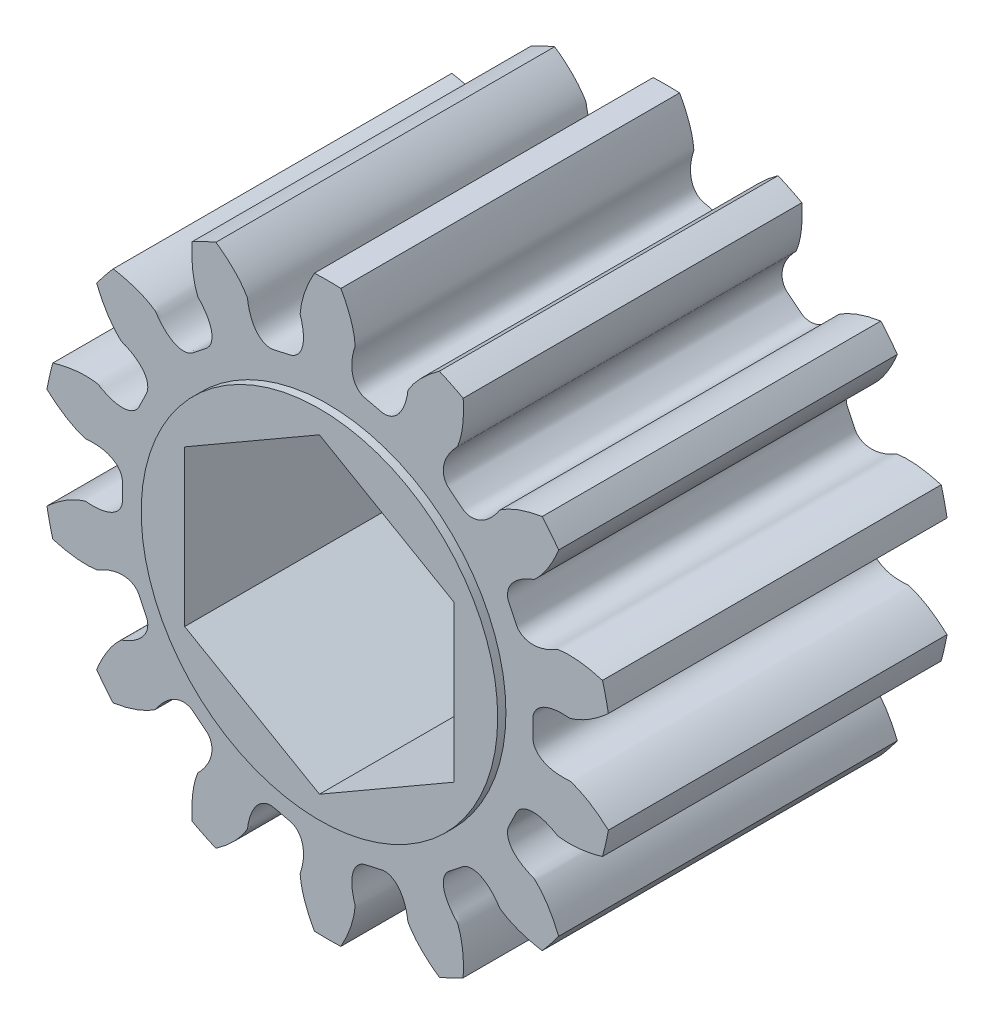
from build123d import *

# Parameters (mm, degrees)
BOSS_EXTRUDE1_DEPTH = 12.065
SKETCH2_R           = 6.35
BOSS_EXTRUDE2_DEPTH = 0.2921
SKETCH3_R           = 6.35
BOSS_EXTRUDE3_DEPTH = 0.2921
CUT_EXTRUDE1_DEPTH  = 13.6492


with BuildPart() as part:
    # Sketch1 → Boss-Extrude1 (new body)
    with BuildSketch(Plane.XY.offset(6.0325)):
        with BuildLine():
            ThreePointArc((8.228776346, 5.959265042), (7.943407862, 6.334656387), (7.640928824, 6.69640252))
            add(Edge.make_bspline(
                [(4.82824311, 8.939444528), (4.833892588, 8.852687386), (4.83956114, 8.714236491), (4.839397518, 8.527056628), (4.834597301, 8.381215605), (4.825704165, 8.244427954), (4.813292608, 8.116797302), (4.797939964, 7.998399272), (4.780222678, 7.889283272), (4.760723014, 7.789466905), (4.740002099, 7.698954413), (4.718682579, 7.617677092), (4.697178715, 7.545684876), (4.676542333, 7.482543191), (4.650701206, 7.415927439), (4.621669261, 7.324730091), (4.540040809, 7.261231409), (4.481952223, 7.188233595), (4.43551344, 7.130936279), (4.39285588, 7.073433212), (4.35314075, 7.016307214), (4.316544651, 6.959436941), (4.282987183, 6.902864935), (4.252459951, 6.846571912), (4.224945594, 6.790531236), (4.200443436, 6.734690952), (4.178969629, 6.678974044), (4.160566483, 6.623273893), (4.145313008, 6.567451505), (4.133339922, 6.5113341), (4.12484958, 6.454717507), (4.120141721, 6.397375872), (4.119644468, 6.339084418), (4.123947256, 6.279663842), (4.133825193, 6.219056118), (4.150237388, 6.157442121), (4.174255479, 6.095387744), (4.206926479, 6.034019633), (4.248882322, 5.975011401), (4.295645816, 5.925851012), (4.399067692, 5.839116758), (4.564695196, 5.723946729), (4.713833258, 5.588099595), (4.821406436, 5.506570908), (4.879740128, 5.471919088), (4.946604954, 5.444145733), (5.01370442, 5.425949552), (5.079547492, 5.416342044), (5.143268754, 5.41405174), (5.204554963, 5.417907952), (5.263443202, 5.426935365), (5.320162519, 5.44039122), (5.375018882, 5.457740758), (5.4283267, 5.478616606), (5.480372862, 5.502776799), (5.531401448, 5.530069487), (5.581609996, 5.560405678), (5.631151593, 5.593739269), (5.680139601, 5.63005274), (5.7286527, 5.669347478), (5.776741391, 5.711635705), (5.82442778, 5.756940272), (5.871728798, 5.805273657), (5.918585081, 5.856704777), (5.965154226, 5.911088458), (6.010681377, 5.969112777), (6.068923056, 6.041988502), (6.112665655, 6.135700144), (6.195116279, 6.184297517), (6.254311643, 6.224314153), (6.311278208, 6.258483483), (6.376680368, 6.295467976), (6.451175858, 6.334338877), (6.534808176, 6.374681199), (6.627782855, 6.415903197), (6.730220622, 6.457456868), (6.842233881, 6.498770629), (6.963902735, 6.539271495), (7.095281925, 6.578379777), (7.23639826, 6.615512324), (7.418848724, 6.657323281), (7.555089737, 6.682605074), (7.640928824, 6.69640252)],
                knots=[0.010313213, 0.010313213, 0.010313213, 0.010313213, 0.046086444, 0.067310464, 0.087321683, 0.106120101, 0.123705718, 0.140078533, 0.155238548, 0.169185761, 0.181920174, 0.193441785, 0.203750595, 0.212846604, 0.220729812, 0.233281794, 0.251264484, 0.261666579, 0.271771633, 0.281588016, 0.291125391, 0.300394957, 0.309409753, 0.318185016, 0.32673863, 0.335091659, 0.343268986, 0.351300066, 0.359219801, 0.367069473, 0.374897695, 0.382761153, 0.390724829, 0.398861066, 0.407246569, 0.415956082, 0.425051594, 0.434566975, 0.44449066, 0.454752968, 0.462386324, 0.5, 0.537613676, 0.545247032, 0.55550934, 0.565433025, 0.574948406, 0.584043918, 0.592753431, 0.601138934, 0.609275171, 0.617238847, 0.625102305, 0.632930527, 0.640780199, 0.648699934, 0.656731014, 0.664908341, 0.67326137, 0.681814984, 0.690590247, 0.699605043, 0.708874609, 0.718411984, 0.728228367, 0.738333421, 0.748735516, 0.766718206, 0.779270188, 0.787153396, 0.796249405, 0.806558215, 0.818079826, 0.830814239, 0.844761452, 0.859921467, 0.876294282, 0.893879899, 0.912678317, 0.932689536, 0.953913556, 0.989686787, 0.989686787, 0.989686787, 0.989686787], degree=3))
            ThreePointArc((4.82824311, 8.939444528), (4.408258789, 9.153843698), (3.978778828, 9.348524966))
            add(Edge.make_bspline(
                [(0.471417111, 10.14905739), (0.514149629, 10.073343122), (0.579328409, 9.951062669), (0.66039529, 9.782348447), (0.719348491, 9.648867489), (0.770685991, 9.521767488), (0.814880429, 9.40139107), (0.852419155, 9.288056869), (0.883800089, 9.182059508), (0.909540197, 9.083667481), (0.930143197, 8.993128076), (0.946199881, 8.910649547), (0.958061821, 8.836456624), (0.966865234, 8.770614142), (0.972486674, 8.699383378), (0.985898842, 8.604620918), (0.939905194, 8.511993324), (0.919241751, 8.421020874), (0.902262226, 8.349248743), (0.888778739, 8.278931848), (0.877782684, 8.210231353), (0.869485825, 8.143114555), (0.863797265, 8.077584899), (0.860717807, 8.013621369), (0.860243365, 7.951192432), (0.862395875, 7.890250987), (0.867223304, 7.830734652), (0.874810032, 7.772565723), (0.885287552, 7.715653255), (0.898848604, 7.659898293), (0.91576409, 7.605204685), (0.936402058, 7.551498993), (0.961245763, 7.498764457), (0.990904063, 7.447095278), (1.026100482, 7.396775482), (1.06762067, 7.348384173), (1.116184607, 7.30289617), (1.172246787, 7.261780829), (1.235650407, 7.226820207), (1.299112753, 7.202818146), (1.429925226, 7.169546354), (1.629120853, 7.137644824), (1.822431467, 7.079959365), (1.954725523, 7.053178809), (2.022317225, 7.047268639), (2.094610758, 7.051257271), (2.162960315, 7.063976446), (2.226451415, 7.083888618), (2.284856014, 7.109472745), (2.338399833, 7.139538162), (2.387539455, 7.173222229), (2.432803517, 7.209955125), (2.47469971, 7.249387802), (2.513670703, 7.291325687), (2.55007996, 7.335675252), (2.584213274, 7.382405588), (2.616287232, 7.431522224), (2.646459766, 7.483050046), (2.674840612, 7.537022452), (2.701500055, 7.593474833), (2.726478295, 7.652440109), (2.749785332, 7.713948463), (2.771431007, 7.778018481), (2.791331932, 7.844686497), (2.809693087, 7.913890096), (2.825535825, 7.985921691), (2.846390172, 8.076850568), (2.845140934, 8.180261043), (2.89834077, 8.259819748), (2.934311383, 8.321557397), (2.970810967, 8.377059766), (3.013689307, 8.438758577), (3.063941972, 8.50610243), (3.12178821, 8.578736309), (3.187669946, 8.656216247), (3.261933723, 8.738100893), (3.344928813, 8.823924037), (3.436975996, 8.913204193), (3.538376109, 9.005442832), (3.649406325, 9.100126183), (3.795647418, 9.216958844), (3.90742697, 9.298849712), (3.978778828, 9.348524966)],
                knots=[0.010313213, 0.010313213, 0.010313213, 0.010313213, 0.046086444, 0.067310464, 0.087321683, 0.106120101, 0.123705718, 0.140078533, 0.155238548, 0.169185761, 0.181920174, 0.193441785, 0.203750595, 0.212846604, 0.220729812, 0.233281794, 0.251264484, 0.261666579, 0.271771633, 0.281588016, 0.291125391, 0.300394957, 0.309409753, 0.318185016, 0.32673863, 0.335091659, 0.343268986, 0.351300066, 0.359219801, 0.367069473, 0.374897695, 0.382761153, 0.390724829, 0.398861066, 0.407246569, 0.415956082, 0.425051594, 0.434566975, 0.44449066, 0.454752968, 0.462386324, 0.5, 0.537613676, 0.545247032, 0.55550934, 0.565433025, 0.574948406, 0.584043918, 0.592753431, 0.601138934, 0.609275171, 0.617238847, 0.625102305, 0.632930527, 0.640780199, 0.648699934, 0.656731014, 0.664908341, 0.67326137, 0.681814984, 0.690590247, 0.699605043, 0.708874609, 0.718411984, 0.728228367, 0.738333421, 0.748735516, 0.766718206, 0.779270188, 0.787153396, 0.796249405, 0.806558215, 0.818079826, 0.830814239, 0.844761452, 0.859921467, 0.876294282, 0.893879899, 0.912678317, 0.932689536, 0.953913556, 0.989686787, 0.989686787, 0.989686787, 0.989686787], degree=3))
            ThreePointArc((0.471417111, 10.14905739), (0, 10.16), (-0.471417111, 10.14905739))
            add(Edge.make_bspline(
                [(-3.978778828, 9.348524966), (-3.90742697, 9.298849712), (-3.795647418, 9.216958844), (-3.649406325, 9.100126183), (-3.538376109, 9.005442832), (-3.436975996, 8.913204193), (-3.344928813, 8.823924037), (-3.261933723, 8.738100893), (-3.187669946, 8.656216247), (-3.12178821, 8.578736309), (-3.063941972, 8.50610243), (-3.013689307, 8.438758577), (-2.970810967, 8.377059766), (-2.934311383, 8.321557397), (-2.89834077, 8.259819748), (-2.845140934, 8.180261043), (-2.846390172, 8.076850568), (-2.825535825, 7.985921691), (-2.809693087, 7.913890096), (-2.791331932, 7.844686497), (-2.771431007, 7.778018481), (-2.749785332, 7.713948463), (-2.726478295, 7.652440109), (-2.701500055, 7.593474833), (-2.674840612, 7.537022452), (-2.646459766, 7.483050046), (-2.616287232, 7.431522224), (-2.584213274, 7.382405588), (-2.55007996, 7.335675252), (-2.513670703, 7.291325687), (-2.47469971, 7.249387802), (-2.432803517, 7.209955125), (-2.387539455, 7.173222229), (-2.338399833, 7.139538162), (-2.284856014, 7.109472745), (-2.226451415, 7.083888618), (-2.162960315, 7.063976446), (-2.094610758, 7.051257271), (-2.022317225, 7.047268639), (-1.954725523, 7.053178809), (-1.822431467, 7.079959365), (-1.629120854, 7.137644824), (-1.429925226, 7.169546354), (-1.299112753, 7.202818146), (-1.235650407, 7.226820207), (-1.172246787, 7.261780829), (-1.116184607, 7.30289617), (-1.06762067, 7.348384173), (-1.026100482, 7.396775482), (-0.990904063, 7.447095278), (-0.961245763, 7.498764457), (-0.936402058, 7.551498993), (-0.91576409, 7.605204685), (-0.898848604, 7.659898293), (-0.885287552, 7.715653255), (-0.874810032, 7.772565723), (-0.867223304, 7.830734652), (-0.862395875, 7.890250987), (-0.860243365, 7.951192432), (-0.860717807, 8.013621369), (-0.863797265, 8.077584899), (-0.869485825, 8.143114555), (-0.877782684, 8.210231353), (-0.888778739, 8.278931848), (-0.902262226, 8.349248743), (-0.919241751, 8.421020874), (-0.939905194, 8.511993324), (-0.985898842, 8.604620918), (-0.972486674, 8.699383378), (-0.966865234, 8.770614142), (-0.958061821, 8.836456624), (-0.946199881, 8.910649547), (-0.930143197, 8.993128076), (-0.909540197, 9.083667481), (-0.883800089, 9.182059508), (-0.852419155, 9.288056869), (-0.814880429, 9.40139107), (-0.770685991, 9.521767488), (-0.719348492, 9.648867489), (-0.66039529, 9.782348447), (-0.579328409, 9.951062669), (-0.514149629, 10.073343122), (-0.471417111, 10.14905739)],
                knots=[0.010313213, 0.010313213, 0.010313213, 0.010313213, 0.046086444, 0.067310464, 0.087321683, 0.106120101, 0.123705718, 0.140078533, 0.155238548, 0.169185761, 0.181920174, 0.193441785, 0.203750595, 0.212846604, 0.220729812, 0.233281794, 0.251264484, 0.261666579, 0.271771633, 0.281588016, 0.291125391, 0.300394957, 0.309409753, 0.318185016, 0.32673863, 0.335091659, 0.343268986, 0.351300066, 0.359219801, 0.367069473, 0.374897695, 0.382761153, 0.390724829, 0.398861066, 0.407246569, 0.415956082, 0.425051594, 0.434566975, 0.44449066, 0.454752968, 0.462386324, 0.5, 0.537613676, 0.545247032, 0.55550934, 0.565433025, 0.574948406, 0.584043918, 0.592753431, 0.601138934, 0.609275171, 0.617238847, 0.625102305, 0.632930527, 0.640780199, 0.648699934, 0.656731014, 0.664908341, 0.67326137, 0.681814984, 0.690590247, 0.699605043, 0.708874609, 0.718411984, 0.728228367, 0.738333421, 0.748735516, 0.766718206, 0.779270188, 0.787153396, 0.796249405, 0.806558215, 0.818079826, 0.830814239, 0.844761452, 0.859921467, 0.876294282, 0.893879899, 0.912678317, 0.932689536, 0.953913556, 0.989686787, 0.989686787, 0.989686787, 0.989686787], degree=3))
            ThreePointArc((-3.978778828, 9.348524966), (-4.408258789, 9.153843698), (-4.82824311, 8.939444528))
            add(Edge.make_bspline(
                [(-7.640928824, 6.69640252), (-7.555089737, 6.682605074), (-7.418848724, 6.657323281), (-7.23639826, 6.615512324), (-7.095281925, 6.578379777), (-6.963902735, 6.539271495), (-6.842233881, 6.498770629), (-6.730220622, 6.457456868), (-6.627782855, 6.415903197), (-6.534808176, 6.374681199), (-6.451175858, 6.334338877), (-6.376680368, 6.295467976), (-6.311278208, 6.258483483), (-6.254311643, 6.224314153), (-6.195116279, 6.184297517), (-6.112665655, 6.135700144), (-6.068923056, 6.041988502), (-6.010681377, 5.969112777), (-5.965154226, 5.911088458), (-5.918585081, 5.856704777), (-5.871728798, 5.805273657), (-5.82442778, 5.756940272), (-5.776741391, 5.711635705), (-5.7286527, 5.669347478), (-5.680139601, 5.63005274), (-5.631151593, 5.59373927), (-5.581609996, 5.560405678), (-5.531401448, 5.530069487), (-5.480372862, 5.502776799), (-5.4283267, 5.478616606), (-5.375018882, 5.457740758), (-5.320162519, 5.44039122), (-5.263443202, 5.426935365), (-5.204554963, 5.417907952), (-5.143268754, 5.41405174), (-5.079547492, 5.416342044), (-5.01370442, 5.425949552), (-4.946604954, 5.444145733), (-4.879740128, 5.471919088), (-4.821406436, 5.506570908), (-4.713833258, 5.588099595), (-4.564695196, 5.723946729), (-4.399067692, 5.839116758), (-4.295645816, 5.925851012), (-4.248882322, 5.975011401), (-4.206926479, 6.034019633), (-4.174255479, 6.095387744), (-4.150237388, 6.157442121), (-4.133825193, 6.219056118), (-4.123947257, 6.279663842), (-4.119644468, 6.339084418), (-4.120141721, 6.397375872), (-4.12484958, 6.454717507), (-4.133339922, 6.5113341), (-4.145313008, 6.567451505), (-4.160566483, 6.623273893), (-4.178969629, 6.678974044), (-4.200443436, 6.734690952), (-4.224945594, 6.790531236), (-4.252459951, 6.846571912), (-4.282987183, 6.902864935), (-4.316544651, 6.959436941), (-4.35314075, 7.016307214), (-4.39285588, 7.073433212), (-4.43551344, 7.130936279), (-4.481952223, 7.188233595), (-4.540040809, 7.261231409), (-4.621669261, 7.324730091), (-4.650701206, 7.415927439), (-4.676542333, 7.482543191), (-4.697178715, 7.545684876), (-4.718682579, 7.617677092), (-4.740002099, 7.698954413), (-4.760723014, 7.789466905), (-4.780222678, 7.889283272), (-4.797939964, 7.998399272), (-4.813292608, 8.116797302), (-4.825704165, 8.244427954), (-4.834597301, 8.381215605), (-4.839397518, 8.527056628), (-4.83956114, 8.714236491), (-4.833892588, 8.852687386), (-4.82824311, 8.939444528)],
                knots=[0.010313213, 0.010313213, 0.010313213, 0.010313213, 0.046086444, 0.067310464, 0.087321683, 0.106120101, 0.123705718, 0.140078533, 0.155238548, 0.169185761, 0.181920174, 0.193441785, 0.203750595, 0.212846604, 0.220729812, 0.233281794, 0.251264484, 0.261666579, 0.271771633, 0.281588016, 0.291125391, 0.300394957, 0.309409753, 0.318185016, 0.32673863, 0.335091659, 0.343268986, 0.351300066, 0.359219801, 0.367069473, 0.374897695, 0.382761153, 0.390724829, 0.398861066, 0.407246569, 0.415956082, 0.425051594, 0.434566975, 0.44449066, 0.454752968, 0.462386324, 0.5, 0.537613676, 0.545247032, 0.55550934, 0.565433025, 0.574948406, 0.584043918, 0.592753431, 0.601138934, 0.609275171, 0.617238847, 0.625102305, 0.632930527, 0.640780199, 0.648699934, 0.656731014, 0.664908341, 0.67326137, 0.681814984, 0.690590247, 0.699605043, 0.708874609, 0.718411984, 0.728228367, 0.738333421, 0.748735516, 0.766718206, 0.779270188, 0.787153396, 0.796249405, 0.806558215, 0.818079826, 0.830814239, 0.844761452, 0.859921467, 0.876294282, 0.893879899, 0.912678317, 0.932689536, 0.953913556, 0.989686787, 0.989686787, 0.989686787, 0.989686787], degree=3))
            ThreePointArc((-7.640928824, 6.69640252), (-7.943407862, 6.334656387), (-8.228776346, 5.959265042))
            add(Edge.make_bspline(
                [(-9.789699156, 2.717975429), (-9.706374323, 2.742788544), (-9.572656053, 2.779123196), (-9.390132771, 2.820615114), (-9.246880138, 2.848387928), (-9.111543131, 2.870155878), (-8.984350614, 2.886455996), (-8.865504785, 2.897834316), (-8.755182084, 2.904841833), (-8.653529238, 2.908042297), (-8.560675246, 2.907981824), (-8.476691677, 2.905282734), (-8.401719397, 2.900337791), (-8.335568779, 2.894269154), (-8.264873031, 2.883899317), (-8.169501975, 2.875888583), (-8.089431298, 2.810436512), (-8.005337766, 2.77004787), (-7.939143412, 2.737523256), (-7.873589867, 2.708730847), (-7.809058689, 2.682723189), (-7.745470874, 2.659699456), (-7.682850007, 2.6395718), (-7.62117542, 2.622336326), (-7.56041728, 2.607982034), (-7.500524786, 2.596519828), (-7.441426445, 2.587982593), (-7.383027728, 2.582435302), (-7.325210706, 2.579985914), (-7.26783602, 2.580800315), (-7.210749644, 2.585121221), (-7.153798086, 2.593291112), (-7.096857471, 2.605777395), (-7.039884153, 2.623194626), (-6.98299404, 2.646311389), (-6.926576891, 2.6760225), (-6.871422875, 2.713246805), (-6.818863372, 2.758754365), (-6.770670653, 2.812788854), (-6.733148673, 2.869319105), (-6.671602561, 2.989448166), (-6.596175672, 3.176550785), (-6.49692085, 3.352178476), (-6.441373542, 3.475196409), (-6.420570983, 3.539778309), (-6.408372787, 3.611146847), (-6.405563859, 3.68061302), (-6.410848692, 3.746943141), (-6.422795126, 3.809576419), (-6.440192119, 3.868467967), (-6.462097062, 3.923870966), (-6.487836786, 3.976174002), (-6.516958024, 4.025794366), (-6.549172576, 4.073120332), (-6.584308384, 4.11848544), (-6.622271716, 4.162161438), (-6.663019767, 4.204360715), (-6.706541659, 4.245242779), (-6.752845532, 4.284922048), (-6.80195025, 4.32347492), (-6.853878962, 4.360947912), (-6.90865887, 4.397357489), (-6.966305902, 4.432717382), (-7.02687404, 4.466954379), (-7.090256819, 4.500254431), (-7.156957091, 4.531728495), (-7.240965662, 4.57229356), (-7.342061402, 4.594086638), (-7.407787327, 4.66365612), (-7.45997287, 4.712462794), (-7.505961757, 4.760397696), (-7.556572321, 4.815930264), (-7.611045453, 4.879908407), (-7.668986251, 4.952466877), (-7.729863539, 5.033937729), (-7.793169921, 5.124560606), (-7.858373155, 5.224572282), (-7.924932446, 5.334178353), (-7.992294822, 5.453561182), (-8.059897717, 5.582876666), (-8.141259434, 5.751448903), (-8.196223837, 5.878648341), (-8.228776346, 5.959265042)],
                knots=[0.010313213, 0.010313213, 0.010313213, 0.010313213, 0.046086444, 0.067310464, 0.087321683, 0.106120101, 0.123705718, 0.140078533, 0.155238548, 0.169185761, 0.181920174, 0.193441785, 0.203750595, 0.212846604, 0.220729812, 0.233281794, 0.251264484, 0.261666579, 0.271771633, 0.281588016, 0.291125391, 0.300394957, 0.309409753, 0.318185016, 0.32673863, 0.335091659, 0.343268986, 0.351300066, 0.359219801, 0.367069473, 0.374897695, 0.382761153, 0.390724829, 0.398861066, 0.407246569, 0.415956082, 0.425051594, 0.434566975, 0.44449066, 0.454752968, 0.462386324, 0.5, 0.537613676, 0.545247032, 0.55550934, 0.565433025, 0.574948406, 0.584043918, 0.592753431, 0.601138934, 0.609275171, 0.617238847, 0.625102305, 0.632930527, 0.640780199, 0.648699934, 0.656731014, 0.664908341, 0.67326137, 0.681814984, 0.690590247, 0.699605043, 0.708874609, 0.718411984, 0.728228367, 0.738333421, 0.748735516, 0.766718206, 0.779270188, 0.787153396, 0.796249405, 0.806558215, 0.818079826, 0.830814239, 0.844761452, 0.859921467, 0.876294282, 0.893879899, 0.912678317, 0.932689536, 0.953913556, 0.989686787, 0.989686787, 0.989686787, 0.989686787], degree=3))
            ThreePointArc((-9.789699156, 2.717975429), (-9.905267588, 2.260812689), (-9.999499508, 1.798780029))
            add(Edge.make_bspline(
                [(-9.999499508, -1.798780029), (-9.935192434, -1.740270896), (-9.830481451, -1.649516322), (-9.684036324, -1.532939511), (-9.567020335, -1.445762082), (-9.454530664, -1.36742931), (-9.347006522, -1.297556647), (-9.244866998, -1.235739863), (-9.148510127, -1.181559082), (-9.058312707, -1.134570046), (-8.974627912, -1.094336693), (-8.89779024, -1.060329384), (-8.828097019, -1.03225537), (-8.765864289, -1.009021346), (-8.697670317, -0.987690511), (-8.608268238, -0.953527983), (-8.507728461, -0.977756896), (-8.414438832, -0.977658989), (-8.340687878, -0.978242), (-8.269133617, -0.975740447), (-8.199708734, -0.971173509), (-8.13242847, -0.964327456), (-8.067275956, -0.955291671), (-8.00423088, -0.944060697), (-7.943261594, -0.930631498), (-7.884327057, -0.914972209), (-7.827377124, -0.897022183), (-7.772354818, -0.876681866), (-7.719200732, -0.853802823), (-7.667861282, -0.828175129), (-7.618303005, -0.799513277), (-7.570536207, -0.767442106), (-7.524652081, -0.731486746), (-7.480877949, -0.691074567), (-7.439651715, -0.645563388), (-7.401712789, -0.594316118), (-7.368171757, -0.536847748), (-7.340562272, -0.47304214), (-7.320586818, -0.40344871), (-7.31130824, -0.336236537), (-7.307979155, -0.201300135), (-7.32120266, 0), (-7.307979155, 0.201300135), (-7.31130824, 0.336236537), (-7.320586818, 0.40344871), (-7.340562272, 0.47304214), (-7.368171757, 0.536847748), (-7.401712789, 0.594316118), (-7.439651715, 0.645563388), (-7.480877949, 0.691074567), (-7.524652081, 0.731486746), (-7.570536207, 0.767442106), (-7.618303005, 0.799513277), (-7.667861282, 0.828175129), (-7.719200732, 0.853802823), (-7.772354818, 0.876681866), (-7.827377124, 0.897022183), (-7.884327057, 0.914972209), (-7.943261594, 0.930631498), (-8.00423088, 0.944060697), (-8.067275956, 0.955291671), (-8.13242847, 0.964327456), (-8.199708734, 0.971173509), (-8.269133617, 0.975740447), (-8.340687878, 0.978242), (-8.414438832, 0.977658989), (-8.507728461, 0.977756896), (-8.608268238, 0.953527983), (-8.697670317, 0.987690511), (-8.765864289, 1.009021346), (-8.828097019, 1.03225537), (-8.89779024, 1.060329384), (-8.974627912, 1.094336693), (-9.058312707, 1.134570046), (-9.148510127, 1.181559082), (-9.244866998, 1.235739863), (-9.347006522, 1.297556647), (-9.454530664, 1.36742931), (-9.567020335, 1.445762082), (-9.684036324, 1.532939511), (-9.830481451, 1.649516322), (-9.935192434, 1.740270896), (-9.999499508, 1.798780029)],
                knots=[0.010313213, 0.010313213, 0.010313213, 0.010313213, 0.046086444, 0.067310464, 0.087321683, 0.106120101, 0.123705718, 0.140078533, 0.155238548, 0.169185761, 0.181920174, 0.193441785, 0.203750595, 0.212846604, 0.220729812, 0.233281794, 0.251264484, 0.261666579, 0.271771633, 0.281588016, 0.291125391, 0.300394957, 0.309409753, 0.318185016, 0.32673863, 0.335091659, 0.343268986, 0.351300066, 0.359219801, 0.367069473, 0.374897695, 0.382761153, 0.390724829, 0.398861066, 0.407246569, 0.415956082, 0.425051594, 0.434566975, 0.44449066, 0.454752968, 0.462386324, 0.5, 0.537613676, 0.545247032, 0.55550934, 0.565433025, 0.574948406, 0.584043918, 0.592753431, 0.601138934, 0.609275171, 0.617238847, 0.625102305, 0.632930527, 0.640780199, 0.648699934, 0.656731014, 0.664908341, 0.67326137, 0.681814984, 0.690590247, 0.699605043, 0.708874609, 0.718411984, 0.728228367, 0.738333421, 0.748735516, 0.766718206, 0.779270188, 0.787153396, 0.796249405, 0.806558215, 0.818079826, 0.830814239, 0.844761452, 0.859921467, 0.876294282, 0.893879899, 0.912678317, 0.932689536, 0.953913556, 0.989686787, 0.989686787, 0.989686787, 0.989686787], degree=3))
            ThreePointArc((-9.999499508, -1.798780029), (-9.905267588, -2.260812689), (-9.789699156, -2.717975429))
            add(Edge.make_bspline(
                [(-8.228776346, -5.959265042), (-8.196223837, -5.878648341), (-8.141259434, -5.751448903), (-8.059897717, -5.582876666), (-7.992294822, -5.453561182), (-7.924932446, -5.334178353), (-7.858373155, -5.224572282), (-7.793169921, -5.124560606), (-7.729863539, -5.033937729), (-7.668986251, -4.952466877), (-7.611045453, -4.879908407), (-7.556572321, -4.815930264), (-7.505961757, -4.760397696), (-7.45997287, -4.712462794), (-7.407787327, -4.66365612), (-7.342061402, -4.594086638), (-7.240965662, -4.57229356), (-7.156957091, -4.531728495), (-7.090256819, -4.500254431), (-7.02687404, -4.466954379), (-6.966305902, -4.432717382), (-6.90865887, -4.397357489), (-6.853878962, -4.360947912), (-6.801950249, -4.32347492), (-6.752845532, -4.284922048), (-6.706541659, -4.245242779), (-6.663019767, -4.204360715), (-6.622271716, -4.162161438), (-6.584308383, -4.11848544), (-6.549172576, -4.073120332), (-6.516958024, -4.025794366), (-6.487836786, -3.976174002), (-6.462097062, -3.923870966), (-6.440192119, -3.868467967), (-6.422795126, -3.809576419), (-6.410848692, -3.746943141), (-6.405563859, -3.68061302), (-6.408372787, -3.611146847), (-6.420570983, -3.539778309), (-6.441373542, -3.475196409), (-6.49692085, -3.352178476), (-6.596175672, -3.176550785), (-6.671602561, -2.989448166), (-6.733148673, -2.869319105), (-6.770670653, -2.812788854), (-6.818863372, -2.758754365), (-6.871422875, -2.713246805), (-6.926576891, -2.6760225), (-6.98299404, -2.646311389), (-7.039884153, -2.623194626), (-7.096857471, -2.605777395), (-7.153798086, -2.593291112), (-7.210749644, -2.585121221), (-7.26783602, -2.580800315), (-7.325210706, -2.579985914), (-7.383027728, -2.582435302), (-7.441426445, -2.587982593), (-7.500524786, -2.596519828), (-7.56041728, -2.607982034), (-7.62117542, -2.622336326), (-7.682850007, -2.6395718), (-7.745470874, -2.659699456), (-7.809058689, -2.682723189), (-7.873589867, -2.708730847), (-7.939143412, -2.737523256), (-8.005337766, -2.77004787), (-8.089431298, -2.810436512), (-8.169501975, -2.875888583), (-8.264873031, -2.883899317), (-8.335568779, -2.894269154), (-8.401719397, -2.900337791), (-8.476691677, -2.905282734), (-8.560675246, -2.907981824), (-8.653529238, -2.908042297), (-8.755182084, -2.904841833), (-8.865504785, -2.897834316), (-8.984350614, -2.886455996), (-9.111543131, -2.870155878), (-9.246880138, -2.848387928), (-9.390132771, -2.820615114), (-9.572656053, -2.779123196), (-9.706374323, -2.742788544), (-9.789699156, -2.717975429)],
                knots=[0.010313213, 0.010313213, 0.010313213, 0.010313213, 0.046086444, 0.067310464, 0.087321683, 0.106120101, 0.123705718, 0.140078533, 0.155238548, 0.169185761, 0.181920174, 0.193441785, 0.203750595, 0.212846604, 0.220729812, 0.233281794, 0.251264484, 0.261666579, 0.271771633, 0.281588016, 0.291125391, 0.300394957, 0.309409753, 0.318185016, 0.32673863, 0.335091659, 0.343268986, 0.351300066, 0.359219801, 0.367069473, 0.374897695, 0.382761153, 0.390724829, 0.398861066, 0.407246569, 0.415956082, 0.425051594, 0.434566975, 0.44449066, 0.454752968, 0.462386324, 0.5, 0.537613676, 0.545247032, 0.55550934, 0.565433025, 0.574948406, 0.584043918, 0.592753431, 0.601138934, 0.609275171, 0.617238847, 0.625102305, 0.632930527, 0.640780199, 0.648699934, 0.656731014, 0.664908341, 0.67326137, 0.681814984, 0.690590247, 0.699605043, 0.708874609, 0.718411984, 0.728228367, 0.738333421, 0.748735516, 0.766718206, 0.779270188, 0.787153396, 0.796249405, 0.806558215, 0.818079826, 0.830814239, 0.844761452, 0.859921467, 0.876294282, 0.893879899, 0.912678317, 0.932689536, 0.953913556, 0.989686787, 0.989686787, 0.989686787, 0.989686787], degree=3))
            ThreePointArc((-8.228776346, -5.959265042), (-7.943407862, -6.334656387), (-7.640928824, -6.69640252))
            add(Edge.make_bspline(
                [(-4.82824311, -8.939444528), (-4.833892588, -8.852687386), (-4.83956114, -8.714236491), (-4.839397518, -8.527056628), (-4.834597301, -8.381215605), (-4.825704165, -8.244427954), (-4.813292608, -8.116797302), (-4.797939964, -7.998399272), (-4.780222678, -7.889283272), (-4.760723014, -7.789466905), (-4.740002099, -7.698954413), (-4.718682579, -7.617677092), (-4.697178715, -7.545684876), (-4.676542333, -7.482543191), (-4.650701206, -7.415927439), (-4.621669261, -7.324730091), (-4.540040809, -7.261231409), (-4.481952223, -7.188233595), (-4.43551344, -7.130936279), (-4.39285588, -7.073433212), (-4.35314075, -7.016307214), (-4.316544651, -6.959436941), (-4.282987183, -6.902864935), (-4.252459951, -6.846571912), (-4.224945594, -6.790531236), (-4.200443436, -6.734690952), (-4.178969629, -6.678974044), (-4.160566483, -6.623273893), (-4.145313008, -6.567451505), (-4.133339922, -6.5113341), (-4.12484958, -6.454717507), (-4.120141721, -6.397375872), (-4.119644468, -6.339084418), (-4.123947257, -6.279663842), (-4.133825193, -6.219056118), (-4.150237388, -6.157442121), (-4.174255479, -6.095387744), (-4.206926479, -6.034019633), (-4.248882322, -5.975011401), (-4.295645816, -5.925851012), (-4.399067692, -5.839116758), (-4.564695196, -5.723946729), (-4.713833258, -5.588099595), (-4.821406436, -5.506570908), (-4.879740128, -5.471919088), (-4.946604954, -5.444145733), (-5.01370442, -5.425949552), (-5.079547492, -5.416342044), (-5.143268754, -5.41405174), (-5.204554963, -5.417907952), (-5.263443202, -5.426935365), (-5.320162519, -5.44039122), (-5.375018882, -5.457740758), (-5.4283267, -5.478616606), (-5.480372862, -5.502776799), (-5.531401448, -5.530069487), (-5.581609996, -5.560405678), (-5.631151593, -5.59373927), (-5.680139601, -5.63005274), (-5.7286527, -5.669347478), (-5.776741391, -5.711635705), (-5.82442778, -5.756940272), (-5.871728798, -5.805273657), (-5.918585081, -5.856704777), (-5.965154226, -5.911088458), (-6.010681377, -5.969112777), (-6.068923056, -6.041988502), (-6.112665655, -6.135700144), (-6.195116279, -6.184297517), (-6.254311643, -6.224314153), (-6.311278208, -6.258483483), (-6.376680368, -6.295467976), (-6.451175858, -6.334338877), (-6.534808176, -6.374681199), (-6.627782855, -6.415903197), (-6.730220622, -6.457456868), (-6.842233881, -6.498770629), (-6.963902735, -6.539271495), (-7.095281925, -6.578379777), (-7.23639826, -6.615512324), (-7.418848724, -6.657323281), (-7.555089737, -6.682605074), (-7.640928824, -6.69640252)],
                knots=[0.010313213, 0.010313213, 0.010313213, 0.010313213, 0.046086444, 0.067310464, 0.087321683, 0.106120101, 0.123705718, 0.140078533, 0.155238548, 0.169185761, 0.181920174, 0.193441785, 0.203750595, 0.212846604, 0.220729812, 0.233281794, 0.251264484, 0.261666579, 0.271771633, 0.281588016, 0.291125391, 0.300394957, 0.309409753, 0.318185016, 0.32673863, 0.335091659, 0.343268986, 0.351300066, 0.359219801, 0.367069473, 0.374897695, 0.382761153, 0.390724829, 0.398861066, 0.407246569, 0.415956082, 0.425051594, 0.434566975, 0.44449066, 0.454752968, 0.462386324, 0.5, 0.537613676, 0.545247032, 0.55550934, 0.565433025, 0.574948406, 0.584043918, 0.592753431, 0.601138934, 0.609275171, 0.617238847, 0.625102305, 0.632930527, 0.640780199, 0.648699934, 0.656731014, 0.664908341, 0.67326137, 0.681814984, 0.690590247, 0.699605043, 0.708874609, 0.718411984, 0.728228367, 0.738333421, 0.748735516, 0.766718206, 0.779270188, 0.787153396, 0.796249405, 0.806558215, 0.818079826, 0.830814239, 0.844761452, 0.859921467, 0.876294282, 0.893879899, 0.912678317, 0.932689536, 0.953913556, 0.989686787, 0.989686787, 0.989686787, 0.989686787], degree=3))
            ThreePointArc((-4.82824311, -8.939444528), (-4.408258789, -9.153843698), (-3.978778828, -9.348524966))
            add(Edge.make_bspline(
                [(-0.471417111, -10.14905739), (-0.514149629, -10.073343122), (-0.579328409, -9.951062669), (-0.66039529, -9.782348447), (-0.719348492, -9.648867489), (-0.770685991, -9.521767488), (-0.814880429, -9.40139107), (-0.852419155, -9.288056869), (-0.883800089, -9.182059508), (-0.909540197, -9.083667481), (-0.930143197, -8.993128076), (-0.946199881, -8.910649547), (-0.958061821, -8.836456624), (-0.966865234, -8.770614142), (-0.972486674, -8.699383378), (-0.985898842, -8.604620918), (-0.939905194, -8.511993324), (-0.919241751, -8.421020874), (-0.902262226, -8.349248743), (-0.888778739, -8.278931848), (-0.877782684, -8.210231353), (-0.869485825, -8.143114555), (-0.863797265, -8.077584899), (-0.860717807, -8.013621369), (-0.860243365, -7.951192432), (-0.862395875, -7.890250987), (-0.867223304, -7.830734652), (-0.874810032, -7.772565723), (-0.885287552, -7.715653255), (-0.898848604, -7.659898293), (-0.91576409, -7.605204685), (-0.936402058, -7.551498993), (-0.961245763, -7.498764457), (-0.990904063, -7.447095278), (-1.026100482, -7.396775482), (-1.06762067, -7.348384173), (-1.116184607, -7.30289617), (-1.172246787, -7.261780829), (-1.235650407, -7.226820207), (-1.299112753, -7.202818146), (-1.429925226, -7.169546354), (-1.629120854, -7.137644824), (-1.822431467, -7.079959365), (-1.954725523, -7.053178809), (-2.022317225, -7.047268639), (-2.094610758, -7.051257271), (-2.162960315, -7.063976446), (-2.226451415, -7.083888618), (-2.284856014, -7.109472746), (-2.338399833, -7.139538162), (-2.387539455, -7.173222229), (-2.432803517, -7.209955125), (-2.47469971, -7.249387802), (-2.513670703, -7.291325687), (-2.55007996, -7.335675252), (-2.584213274, -7.382405588), (-2.616287232, -7.431522224), (-2.646459766, -7.483050046), (-2.674840612, -7.537022452), (-2.701500055, -7.593474833), (-2.726478295, -7.652440109), (-2.749785332, -7.713948463), (-2.771431007, -7.778018481), (-2.791331932, -7.844686497), (-2.809693087, -7.913890096), (-2.825535825, -7.985921691), (-2.846390172, -8.076850568), (-2.845140934, -8.180261043), (-2.89834077, -8.259819748), (-2.934311383, -8.321557397), (-2.970810967, -8.377059766), (-3.013689307, -8.438758577), (-3.063941972, -8.50610243), (-3.12178821, -8.578736309), (-3.187669946, -8.656216247), (-3.261933723, -8.738100893), (-3.344928813, -8.823924037), (-3.436975996, -8.913204193), (-3.538376109, -9.005442832), (-3.649406325, -9.100126183), (-3.795647418, -9.216958844), (-3.90742697, -9.298849712), (-3.978778828, -9.348524966)],
                knots=[0.010313213, 0.010313213, 0.010313213, 0.010313213, 0.046086444, 0.067310464, 0.087321683, 0.106120101, 0.123705718, 0.140078533, 0.155238548, 0.169185761, 0.181920174, 0.193441785, 0.203750595, 0.212846604, 0.220729812, 0.233281794, 0.251264484, 0.261666579, 0.271771633, 0.281588016, 0.291125391, 0.300394957, 0.309409753, 0.318185016, 0.32673863, 0.335091659, 0.343268986, 0.351300066, 0.359219801, 0.367069473, 0.374897695, 0.382761153, 0.390724829, 0.398861066, 0.407246569, 0.415956082, 0.425051594, 0.434566975, 0.44449066, 0.454752968, 0.462386324, 0.5, 0.537613676, 0.545247032, 0.55550934, 0.565433025, 0.574948406, 0.584043918, 0.592753431, 0.601138934, 0.609275171, 0.617238847, 0.625102305, 0.632930527, 0.640780199, 0.648699934, 0.656731014, 0.664908341, 0.67326137, 0.681814984, 0.690590247, 0.699605043, 0.708874609, 0.718411984, 0.728228367, 0.738333421, 0.748735516, 0.766718206, 0.779270188, 0.787153396, 0.796249405, 0.806558215, 0.818079826, 0.830814239, 0.844761452, 0.859921467, 0.876294282, 0.893879899, 0.912678317, 0.932689536, 0.953913556, 0.989686787, 0.989686787, 0.989686787, 0.989686787], degree=3))
            ThreePointArc((-0.471417111, -10.14905739), (0, -10.16), (0.471417111, -10.14905739))
            add(Edge.make_bspline(
                [(3.978778828, -9.348524966), (3.90742697, -9.298849712), (3.795647418, -9.216958844), (3.649406325, -9.100126183), (3.538376109, -9.005442832), (3.436975996, -8.913204193), (3.344928813, -8.823924037), (3.261933723, -8.738100893), (3.187669946, -8.656216247), (3.12178821, -8.578736309), (3.063941972, -8.50610243), (3.013689307, -8.438758577), (2.970810967, -8.377059766), (2.934311383, -8.321557397), (2.89834077, -8.259819748), (2.845140934, -8.180261043), (2.846390172, -8.076850568), (2.825535825, -7.985921691), (2.809693087, -7.913890096), (2.791331932, -7.844686497), (2.771431007, -7.778018481), (2.749785332, -7.713948463), (2.726478295, -7.652440109), (2.701500055, -7.593474833), (2.674840612, -7.537022452), (2.646459766, -7.483050046), (2.616287232, -7.431522224), (2.584213274, -7.382405588), (2.55007996, -7.335675252), (2.513670703, -7.291325687), (2.47469971, -7.249387802), (2.432803517, -7.209955124), (2.387539455, -7.173222229), (2.338399833, -7.139538162), (2.284856014, -7.109472745), (2.226451415, -7.083888618), (2.162960315, -7.063976446), (2.094610758, -7.051257271), (2.022317225, -7.047268639), (1.954725523, -7.053178809), (1.822431467, -7.079959365), (1.629120854, -7.137644824), (1.429925226, -7.169546354), (1.299112753, -7.202818146), (1.235650407, -7.226820207), (1.172246787, -7.261780829), (1.116184607, -7.30289617), (1.06762067, -7.348384173), (1.026100482, -7.396775482), (0.990904063, -7.447095278), (0.961245763, -7.498764457), (0.936402058, -7.551498993), (0.91576409, -7.605204685), (0.898848604, -7.659898293), (0.885287552, -7.715653255), (0.874810032, -7.772565723), (0.867223304, -7.830734652), (0.862395875, -7.890250987), (0.860243365, -7.951192432), (0.860717807, -8.013621369), (0.863797265, -8.077584899), (0.869485825, -8.143114555), (0.877782684, -8.210231353), (0.888778739, -8.278931848), (0.902262226, -8.349248743), (0.919241751, -8.421020874), (0.939905194, -8.511993324), (0.985898842, -8.604620918), (0.972486674, -8.699383378), (0.966865234, -8.770614142), (0.958061821, -8.836456624), (0.946199881, -8.910649547), (0.930143197, -8.993128076), (0.909540197, -9.083667481), (0.883800089, -9.182059508), (0.852419155, -9.288056869), (0.814880429, -9.40139107), (0.770685991, -9.521767488), (0.719348492, -9.648867489), (0.66039529, -9.782348447), (0.579328409, -9.951062669), (0.514149629, -10.073343122), (0.471417111, -10.14905739)],
                knots=[0.010313213, 0.010313213, 0.010313213, 0.010313213, 0.046086444, 0.067310464, 0.087321683, 0.106120101, 0.123705718, 0.140078533, 0.155238548, 0.169185761, 0.181920174, 0.193441785, 0.203750595, 0.212846604, 0.220729812, 0.233281794, 0.251264484, 0.261666579, 0.271771633, 0.281588016, 0.291125391, 0.300394957, 0.309409753, 0.318185016, 0.32673863, 0.335091659, 0.343268986, 0.351300066, 0.359219801, 0.367069473, 0.374897695, 0.382761153, 0.390724829, 0.398861066, 0.407246569, 0.415956082, 0.425051594, 0.434566975, 0.44449066, 0.454752968, 0.462386324, 0.5, 0.537613676, 0.545247032, 0.55550934, 0.565433025, 0.574948406, 0.584043918, 0.592753431, 0.601138934, 0.609275171, 0.617238847, 0.625102305, 0.632930527, 0.640780199, 0.648699934, 0.656731014, 0.664908341, 0.67326137, 0.681814984, 0.690590247, 0.699605043, 0.708874609, 0.718411984, 0.728228367, 0.738333421, 0.748735516, 0.766718206, 0.779270188, 0.787153396, 0.796249405, 0.806558215, 0.818079826, 0.830814239, 0.844761452, 0.859921467, 0.876294282, 0.893879899, 0.912678317, 0.932689536, 0.953913556, 0.989686787, 0.989686787, 0.989686787, 0.989686787], degree=3))
            ThreePointArc((3.978778828, -9.348524966), (4.408258789, -9.153843698), (4.82824311, -8.939444528))
            add(Edge.make_bspline(
                [(7.640928824, -6.69640252), (7.555089737, -6.682605074), (7.418848724, -6.657323281), (7.23639826, -6.615512324), (7.095281925, -6.578379777), (6.963902735, -6.539271495), (6.842233881, -6.498770629), (6.730220622, -6.457456868), (6.627782855, -6.415903197), (6.534808176, -6.374681199), (6.451175858, -6.334338877), (6.376680368, -6.295467976), (6.311278208, -6.258483483), (6.254311643, -6.224314153), (6.195116279, -6.184297517), (6.112665655, -6.135700144), (6.068923056, -6.041988502), (6.010681377, -5.969112777), (5.965154226, -5.911088458), (5.918585081, -5.856704777), (5.871728798, -5.805273657), (5.82442778, -5.756940272), (5.776741391, -5.711635705), (5.7286527, -5.669347478), (5.680139601, -5.63005274), (5.631151593, -5.593739269), (5.581609996, -5.560405678), (5.531401448, -5.530069487), (5.480372862, -5.502776799), (5.4283267, -5.478616606), (5.375018882, -5.457740758), (5.320162519, -5.44039122), (5.263443202, -5.426935365), (5.204554963, -5.417907952), (5.143268754, -5.41405174), (5.079547492, -5.416342044), (5.01370442, -5.425949552), (4.946604954, -5.444145733), (4.879740128, -5.471919088), (4.821406436, -5.506570908), (4.713833258, -5.588099595), (4.564695196, -5.723946729), (4.399067692, -5.839116758), (4.295645816, -5.925851012), (4.248882322, -5.975011401), (4.206926479, -6.034019633), (4.174255479, -6.095387744), (4.150237388, -6.157442121), (4.133825193, -6.219056118), (4.123947257, -6.279663842), (4.119644468, -6.339084418), (4.120141721, -6.397375872), (4.12484958, -6.454717507), (4.133339922, -6.5113341), (4.145313008, -6.567451505), (4.160566483, -6.623273893), (4.178969629, -6.678974044), (4.200443436, -6.734690952), (4.224945594, -6.790531236), (4.252459951, -6.846571912), (4.282987183, -6.902864935), (4.316544651, -6.959436941), (4.35314075, -7.016307214), (4.39285588, -7.073433212), (4.43551344, -7.130936279), (4.481952223, -7.188233595), (4.540040809, -7.261231409), (4.621669261, -7.324730091), (4.650701206, -7.415927439), (4.676542333, -7.482543191), (4.697178715, -7.545684876), (4.718682579, -7.617677092), (4.740002099, -7.698954413), (4.760723014, -7.789466905), (4.780222678, -7.889283272), (4.797939964, -7.998399272), (4.813292608, -8.116797302), (4.825704165, -8.244427954), (4.834597301, -8.381215605), (4.839397518, -8.527056628), (4.83956114, -8.714236491), (4.833892588, -8.852687386), (4.82824311, -8.939444528)],
                knots=[0.010313213, 0.010313213, 0.010313213, 0.010313213, 0.046086444, 0.067310464, 0.087321683, 0.106120101, 0.123705718, 0.140078533, 0.155238548, 0.169185761, 0.181920174, 0.193441785, 0.203750595, 0.212846604, 0.220729812, 0.233281794, 0.251264484, 0.261666579, 0.271771633, 0.281588016, 0.291125391, 0.300394957, 0.309409753, 0.318185016, 0.32673863, 0.335091659, 0.343268986, 0.351300066, 0.359219801, 0.367069473, 0.374897695, 0.382761153, 0.390724829, 0.398861066, 0.407246569, 0.415956082, 0.425051594, 0.434566975, 0.44449066, 0.454752968, 0.462386324, 0.5, 0.537613676, 0.545247032, 0.55550934, 0.565433025, 0.574948406, 0.584043918, 0.592753431, 0.601138934, 0.609275171, 0.617238847, 0.625102305, 0.632930527, 0.640780199, 0.648699934, 0.656731014, 0.664908341, 0.67326137, 0.681814984, 0.690590247, 0.699605043, 0.708874609, 0.718411984, 0.728228367, 0.738333421, 0.748735516, 0.766718206, 0.779270188, 0.787153396, 0.796249405, 0.806558215, 0.818079826, 0.830814239, 0.844761452, 0.859921467, 0.876294282, 0.893879899, 0.912678317, 0.932689536, 0.953913556, 0.989686787, 0.989686787, 0.989686787, 0.989686787], degree=3))
            ThreePointArc((7.640928824, -6.69640252), (7.943407862, -6.334656387), (8.228776346, -5.959265042))
            add(Edge.make_bspline(
                [(9.789699156, -2.717975429), (9.706374323, -2.742788544), (9.572656053, -2.779123196), (9.390132771, -2.820615114), (9.246880138, -2.848387928), (9.111543131, -2.870155878), (8.984350614, -2.886455996), (8.865504785, -2.897834316), (8.755182084, -2.904841833), (8.653529238, -2.908042297), (8.560675246, -2.907981824), (8.476691677, -2.905282734), (8.401719397, -2.900337791), (8.335568779, -2.894269154), (8.264873031, -2.883899317), (8.169501975, -2.875888583), (8.089431298, -2.810436512), (8.005337766, -2.77004787), (7.939143412, -2.737523256), (7.873589867, -2.708730847), (7.809058689, -2.682723189), (7.745470874, -2.659699456), (7.682850007, -2.6395718), (7.62117542, -2.622336326), (7.56041728, -2.607982034), (7.500524786, -2.596519828), (7.441426445, -2.587982593), (7.383027728, -2.582435302), (7.325210706, -2.579985914), (7.26783602, -2.580800315), (7.210749644, -2.585121221), (7.153798086, -2.593291112), (7.096857471, -2.605777395), (7.039884153, -2.623194626), (6.98299404, -2.646311389), (6.926576891, -2.6760225), (6.871422875, -2.713246805), (6.818863372, -2.758754365), (6.770670653, -2.812788854), (6.733148673, -2.869319105), (6.671602561, -2.989448166), (6.596175672, -3.176550785), (6.49692085, -3.352178476), (6.441373542, -3.475196409), (6.420570983, -3.539778309), (6.408372787, -3.611146847), (6.405563859, -3.68061302), (6.410848692, -3.746943141), (6.422795126, -3.809576419), (6.440192119, -3.868467967), (6.462097062, -3.923870966), (6.487836786, -3.976174002), (6.516958024, -4.025794366), (6.549172576, -4.073120332), (6.584308383, -4.11848544), (6.622271716, -4.162161438), (6.663019767, -4.204360715), (6.706541659, -4.245242779), (6.752845532, -4.284922048), (6.801950249, -4.32347492), (6.853878962, -4.360947912), (6.90865887, -4.397357489), (6.966305902, -4.432717382), (7.02687404, -4.466954379), (7.090256819, -4.500254431), (7.156957091, -4.531728495), (7.240965662, -4.57229356), (7.342061402, -4.594086638), (7.407787327, -4.66365612), (7.45997287, -4.712462794), (7.505961757, -4.760397696), (7.556572321, -4.815930264), (7.611045453, -4.879908407), (7.668986251, -4.952466877), (7.729863539, -5.033937729), (7.793169921, -5.124560606), (7.858373155, -5.224572282), (7.924932446, -5.334178353), (7.992294822, -5.453561182), (8.059897717, -5.582876666), (8.141259434, -5.751448903), (8.196223837, -5.878648341), (8.228776346, -5.959265042)],
                knots=[0.010313213, 0.010313213, 0.010313213, 0.010313213, 0.046086444, 0.067310464, 0.087321683, 0.106120101, 0.123705718, 0.140078533, 0.155238548, 0.169185761, 0.181920174, 0.193441785, 0.203750595, 0.212846604, 0.220729812, 0.233281794, 0.251264484, 0.261666579, 0.271771633, 0.281588016, 0.291125391, 0.300394957, 0.309409753, 0.318185016, 0.32673863, 0.335091659, 0.343268986, 0.351300066, 0.359219801, 0.367069473, 0.374897695, 0.382761153, 0.390724829, 0.398861066, 0.407246569, 0.415956082, 0.425051594, 0.434566975, 0.44449066, 0.454752968, 0.462386324, 0.5, 0.537613676, 0.545247032, 0.55550934, 0.565433025, 0.574948406, 0.584043918, 0.592753431, 0.601138934, 0.609275171, 0.617238847, 0.625102305, 0.632930527, 0.640780199, 0.648699934, 0.656731014, 0.664908341, 0.67326137, 0.681814984, 0.690590247, 0.699605043, 0.708874609, 0.718411984, 0.728228367, 0.738333421, 0.748735516, 0.766718206, 0.779270188, 0.787153396, 0.796249405, 0.806558215, 0.818079826, 0.830814239, 0.844761452, 0.859921467, 0.876294282, 0.893879899, 0.912678317, 0.932689536, 0.953913556, 0.989686787, 0.989686787, 0.989686787, 0.989686787], degree=3))
            ThreePointArc((9.789699156, -2.717975429), (9.905267588, -2.260812689), (9.999499508, -1.798780029))
            add(Edge.make_bspline(
                [(9.999499508, 1.798780029), (9.935192434, 1.740270896), (9.830481451, 1.649516323), (9.684036324, 1.532939511), (9.567020334, 1.445762082), (9.454530664, 1.36742931), (9.347006522, 1.297556647), (9.244866998, 1.235739863), (9.148510127, 1.181559082), (9.058312707, 1.134570046), (8.974627912, 1.094336693), (8.89779024, 1.060329384), (8.828097019, 1.03225537), (8.765864289, 1.009021346), (8.697670317, 0.987690511), (8.608268238, 0.953527983), (8.507728461, 0.977756896), (8.414438832, 0.977658989), (8.340687878, 0.978242), (8.269133617, 0.975740447), (8.199708734, 0.971173509), (8.13242847, 0.964327456), (8.067275956, 0.955291671), (8.00423088, 0.944060697), (7.943261594, 0.930631498), (7.884327057, 0.914972209), (7.827377124, 0.897022183), (7.772354818, 0.876681866), (7.719200732, 0.853802823), (7.667861281, 0.828175129), (7.618303005, 0.799513277), (7.570536207, 0.767442106), (7.524652081, 0.731486746), (7.480877948, 0.691074567), (7.439651715, 0.645563388), (7.401712789, 0.594316118), (7.368171757, 0.536847748), (7.340562272, 0.47304214), (7.320586818, 0.40344871), (7.31130824, 0.336236537), (7.307979155, 0.201300135), (7.32120266, 0), (7.307979155, -0.201300135), (7.31130824, -0.336236537), (7.320586818, -0.40344871), (7.340562272, -0.47304214), (7.368171757, -0.536847748), (7.401712789, -0.594316118), (7.439651715, -0.645563388), (7.480877948, -0.691074567), (7.524652081, -0.731486746), (7.570536207, -0.767442106), (7.618303005, -0.799513277), (7.667861281, -0.828175129), (7.719200732, -0.853802823), (7.772354818, -0.876681866), (7.827377124, -0.897022183), (7.884327057, -0.914972209), (7.943261594, -0.930631498), (8.00423088, -0.944060697), (8.067275956, -0.955291671), (8.13242847, -0.964327456), (8.199708734, -0.971173509), (8.269133617, -0.975740447), (8.340687878, -0.978242), (8.414438832, -0.977658989), (8.507728461, -0.977756896), (8.608268238, -0.953527983), (8.697670317, -0.987690511), (8.765864289, -1.009021346), (8.828097019, -1.03225537), (8.89779024, -1.060329384), (8.974627912, -1.094336693), (9.058312707, -1.134570046), (9.148510127, -1.181559082), (9.244866998, -1.235739862), (9.347006522, -1.297556647), (9.454530664, -1.36742931), (9.567020334, -1.445762082), (9.684036324, -1.532939511), (9.830481451, -1.649516322), (9.935192434, -1.740270896), (9.999499508, -1.798780029)],
                knots=[0.010313213, 0.010313213, 0.010313213, 0.010313213, 0.046086444, 0.067310464, 0.087321683, 0.106120101, 0.123705718, 0.140078533, 0.155238548, 0.169185761, 0.181920174, 0.193441785, 0.203750595, 0.212846604, 0.220729812, 0.233281794, 0.251264484, 0.261666579, 0.271771633, 0.281588016, 0.291125391, 0.300394957, 0.309409753, 0.318185016, 0.32673863, 0.335091659, 0.343268986, 0.351300066, 0.359219801, 0.367069473, 0.374897695, 0.382761153, 0.390724829, 0.398861066, 0.407246569, 0.415956082, 0.425051594, 0.434566975, 0.44449066, 0.454752968, 0.462386324, 0.5, 0.537613676, 0.545247032, 0.55550934, 0.565433025, 0.574948406, 0.584043918, 0.592753431, 0.601138934, 0.609275171, 0.617238847, 0.625102305, 0.632930527, 0.640780199, 0.648699934, 0.656731014, 0.664908341, 0.67326137, 0.681814984, 0.690590247, 0.699605043, 0.708874609, 0.718411984, 0.728228367, 0.738333421, 0.748735516, 0.766718206, 0.779270188, 0.787153396, 0.796249405, 0.806558215, 0.818079826, 0.830814239, 0.844761452, 0.859921467, 0.876294282, 0.893879899, 0.912678317, 0.932689536, 0.953913556, 0.989686787, 0.989686787, 0.989686787, 0.989686787], degree=3))
            ThreePointArc((9.999499508, 1.798780029), (9.905267588, 2.260812689), (9.789699156, 2.717975429))
            add(Edge.make_bspline(
                [(8.228776346, 5.959265042), (8.196223837, 5.878648341), (8.141259434, 5.751448903), (8.059897717, 5.582876666), (7.992294822, 5.453561182), (7.924932446, 5.334178353), (7.858373155, 5.224572282), (7.793169921, 5.124560606), (7.729863539, 5.033937729), (7.668986251, 4.952466877), (7.611045453, 4.879908407), (7.556572321, 4.815930264), (7.505961757, 4.760397696), (7.45997287, 4.712462794), (7.407787327, 4.66365612), (7.342061402, 4.594086638), (7.240965662, 4.57229356), (7.156957091, 4.531728495), (7.090256819, 4.500254431), (7.02687404, 4.466954379), (6.966305902, 4.432717382), (6.90865887, 4.397357489), (6.853878962, 4.360947912), (6.801950249, 4.32347492), (6.752845532, 4.284922048), (6.706541659, 4.245242779), (6.663019767, 4.204360715), (6.622271716, 4.162161438), (6.584308383, 4.11848544), (6.549172576, 4.073120332), (6.516958024, 4.025794366), (6.487836786, 3.976174002), (6.462097062, 3.923870966), (6.440192119, 3.868467967), (6.422795126, 3.809576419), (6.410848692, 3.746943141), (6.405563859, 3.68061302), (6.408372787, 3.611146847), (6.420570983, 3.539778309), (6.441373542, 3.475196409), (6.49692085, 3.352178476), (6.596175672, 3.176550785), (6.671602561, 2.989448166), (6.733148673, 2.869319105), (6.770670653, 2.812788854), (6.818863372, 2.758754365), (6.871422875, 2.713246805), (6.926576891, 2.6760225), (6.98299404, 2.646311389), (7.039884153, 2.623194626), (7.096857471, 2.605777395), (7.153798086, 2.593291112), (7.210749644, 2.585121221), (7.26783602, 2.580800315), (7.325210706, 2.579985914), (7.383027728, 2.582435302), (7.441426445, 2.587982593), (7.500524786, 2.596519828), (7.56041728, 2.607982034), (7.62117542, 2.622336326), (7.682850007, 2.6395718), (7.745470874, 2.659699456), (7.809058689, 2.682723189), (7.873589867, 2.708730847), (7.939143412, 2.737523256), (8.005337766, 2.77004787), (8.089431298, 2.810436512), (8.169501975, 2.875888583), (8.264873031, 2.883899317), (8.335568779, 2.894269154), (8.401719397, 2.900337791), (8.476691677, 2.905282734), (8.560675246, 2.907981824), (8.653529238, 2.908042297), (8.755182084, 2.904841833), (8.865504785, 2.897834316), (8.984350614, 2.886455996), (9.111543131, 2.870155878), (9.246880138, 2.848387928), (9.390132771, 2.820615114), (9.572656053, 2.779123196), (9.706374323, 2.742788544), (9.789699156, 2.717975429)],
                knots=[0.010313213, 0.010313213, 0.010313213, 0.010313213, 0.046086444, 0.067310464, 0.087321683, 0.106120101, 0.123705718, 0.140078533, 0.155238548, 0.169185761, 0.181920174, 0.193441785, 0.203750595, 0.212846604, 0.220729812, 0.233281794, 0.251264484, 0.261666579, 0.271771633, 0.281588016, 0.291125391, 0.300394957, 0.309409753, 0.318185016, 0.32673863, 0.335091659, 0.343268986, 0.351300066, 0.359219801, 0.367069473, 0.374897695, 0.382761153, 0.390724829, 0.398861066, 0.407246569, 0.415956082, 0.425051594, 0.434566975, 0.44449066, 0.454752968, 0.462386324, 0.5, 0.537613676, 0.545247032, 0.55550934, 0.565433025, 0.574948406, 0.584043918, 0.592753431, 0.601138934, 0.609275171, 0.617238847, 0.625102305, 0.632930527, 0.640780199, 0.648699934, 0.656731014, 0.664908341, 0.67326137, 0.681814984, 0.690590247, 0.699605043, 0.708874609, 0.718411984, 0.728228367, 0.738333421, 0.748735516, 0.766718206, 0.779270188, 0.787153396, 0.796249405, 0.806558215, 0.818079826, 0.830814239, 0.844761452, 0.859921467, 0.876294282, 0.893879899, 0.912678317, 0.932689536, 0.953913556, 0.989686787, 0.989686787, 0.989686787, 0.989686787], degree=3))
        make_face()
    extrude(amount=-BOSS_EXTRUDE1_DEPTH)

    # Sketch2 → Boss-Extrude2 (add)
    with BuildSketch(Plane.XY.offset(6.0325)):
        Circle(SKETCH2_R)
    extrude(amount=BOSS_EXTRUDE2_DEPTH)

    # Sketch3 → Boss-Extrude3 (add)
    with BuildSketch(Plane(origin=(0, 0, -6.0325), x_dir=(-1, 0, 0), z_dir=(0, 0, -1))):
        Circle(SKETCH3_R)
    extrude(amount=BOSS_EXTRUDE3_DEPTH)

    # Sketch4 → Cut-Extrude1 (cut, through all)
    with BuildSketch(Plane(origin=(0, 0, -6.3246), x_dir=(-1, 0, 0), z_dir=(0, 0, -1))):
        Polygon((-4.8006, 2.771627702), (-4.8006, -2.771627702), (0, -5.543255405), (4.8006, -2.771627702), (4.8006, 2.771627702), (0, 5.543255405), align=None)
    extrude(amount=-CUT_EXTRUDE1_DEPTH, mode=Mode.SUBTRACT)


solid = part.part
